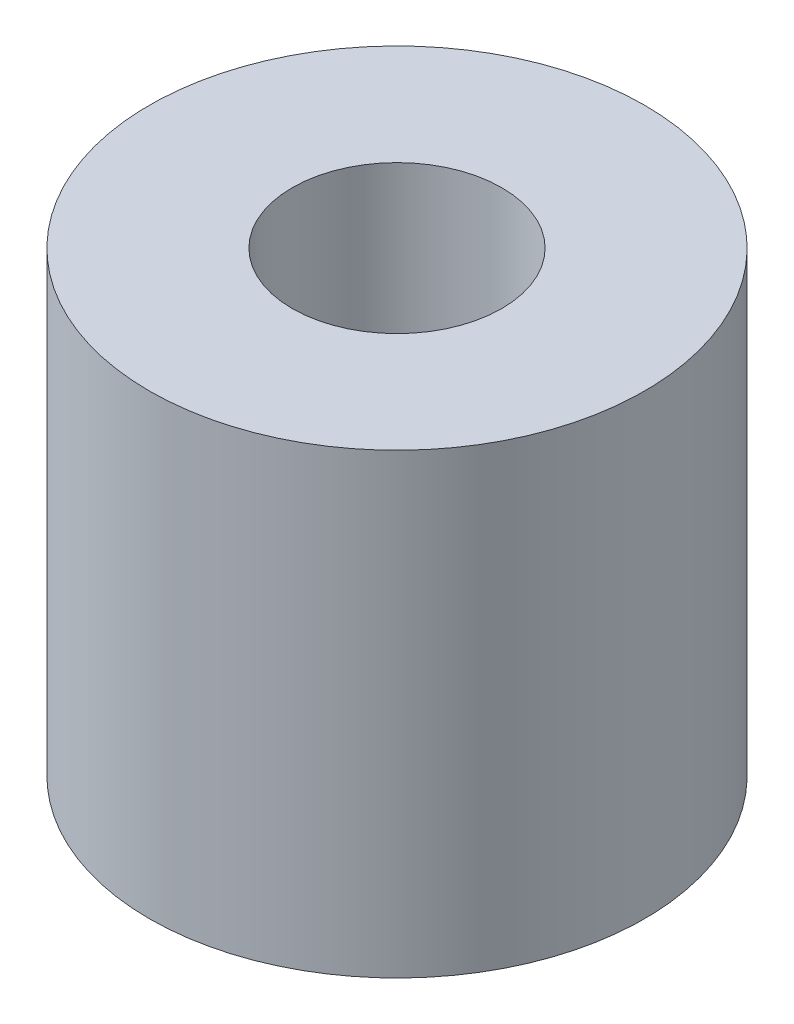
from build123d import *

# Parameters (mm, degrees)
SKETCH1_R           = 3.9
SKETCH1_R_2         = 1.65
BOSS_EXTRUDE1_DEPTH = 7.2


with BuildPart() as part:
    # Sketch1 → Boss-Extrude1 (new body)
    with BuildSketch(Plane(origin=(0, 0, 0), x_dir=(1, 0, 0), z_dir=(0, 1, 0))):
        Circle(SKETCH1_R)
        Circle(SKETCH1_R_2, mode=Mode.SUBTRACT)
    extrude(amount=BOSS_EXTRUDE1_DEPTH)


solid = part.part
